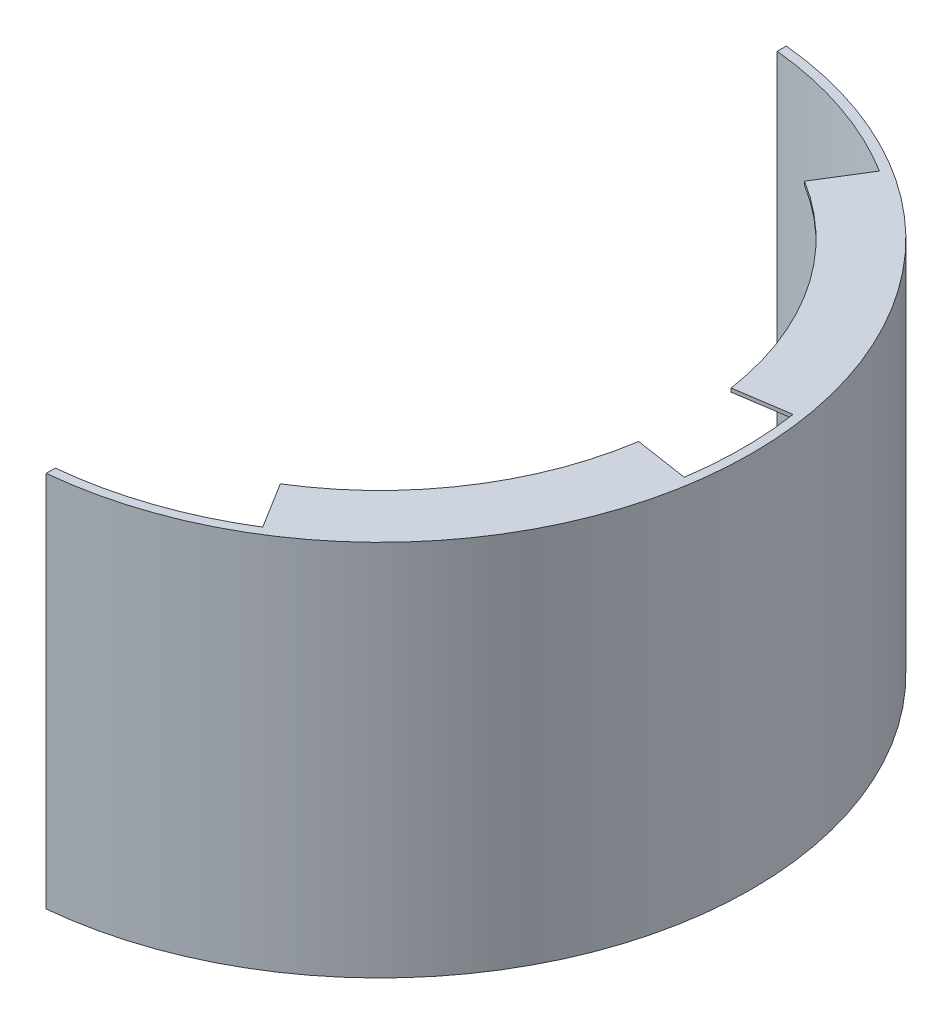
from build123d import *

# Parameters (mm, degrees)
BOSS_EXTRUDE1_DEPTH = 208
BOSS_EXTRUDE2_DEPTH = 2


with BuildPart() as part:
    # Sketch1 → Boss-Extrude1 (new body)
    with BuildSketch(Plane(origin=(0, 0, 0), x_dir=(1, 0, 0), z_dir=(0, 1, 0))):
        with BuildLine():
            Line((20, 204.022057631), (20, 198.997487421))
            ThreePointArc((20, 198.997487421), (200, 0), (20, -198.997487421))
            Line((20, -198.997487421), (20, -204.022057631))
            ThreePointArc((20, -204.022057631), (205, 0), (20, 204.022057631))
        make_face()
    extrude(amount=BOSS_EXTRUDE1_DEPTH)

    # Sketch2 → Boss-Extrude2 (add)
    with BuildSketch(Plane(origin=(0, 0, 0), x_dir=(1, 0, 0), z_dir=(0, 1, 0))):
        with BuildLine():
            Line((105.356537529, -170), (89.553056899, -144.5))
            ThreePointArc((89.553056899, -144.5), (141.892609151, -93.629522418), (168.076619433, -25.5))
            Line((168.076619433, -25.5), (197.737199333, -30))
            ThreePointArc((197.737199333, -30), (166.932481354, -110.152379315), (105.356537529, -170))
        make_face()
        with BuildLine():
            Line((197.737199333, 30), (168.076619433, 25.5))
            ThreePointArc((168.076619433, 25.5), (141.892609151, 93.629522418), (89.553056899, 144.5))
            Line((89.553056899, 144.5), (105.356537529, 170))
            ThreePointArc((105.356537529, 170), (166.932481354, 110.152379315), (197.737199333, 30))
        make_face()
    boss_extrude2 = extrude(amount=BOSS_EXTRUDE2_DEPTH)

    # Mirror1: Boss-Extrude2 across plane
    add(boss_extrude2.mirror(Plane.ZX.offset(104)))


solid = part.part
